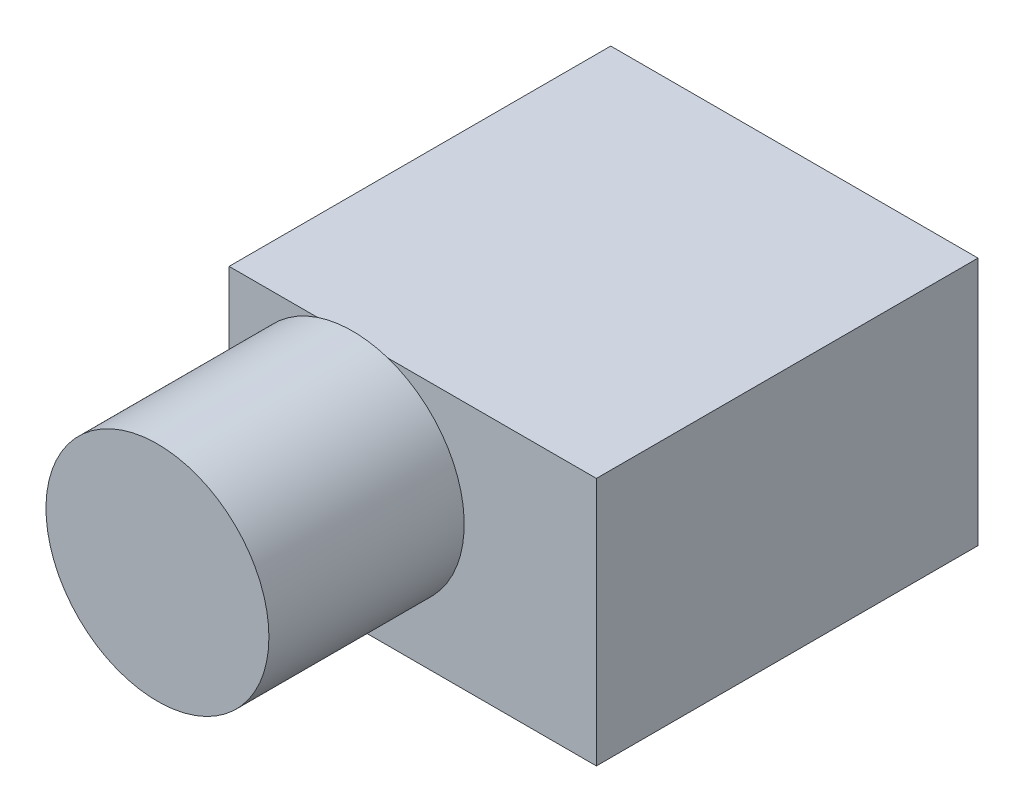
from build123d import *

# Parameters (mm, degrees)
SKETCH1_W           = 20.5
SKETCH1_H           = 21.3
BOSS_EXTRUDE1_DEPTH = 13.9
SKETCH2_R           = 6.221989568
BOSS_EXTRUDE2_DEPTH = 10.9


with BuildPart() as part:
    # Sketch1 → Boss-Extrude1 (new body)
    with BuildSketch(Plane(origin=(0, 0, 0), x_dir=(1, 0, 0), z_dir=(0, 1, 0))):
        Rectangle(SKETCH1_W, SKETCH1_H)
    extrude(amount=BOSS_EXTRUDE1_DEPTH)

    # Sketch2 → Boss-Extrude2 (add)
    with BuildSketch(Plane.XY.offset(10.65)):
        with Locations((-3.349791779, 7.996227622)):
            Circle(SKETCH2_R)
    extrude(amount=BOSS_EXTRUDE2_DEPTH)


solid = part.part
